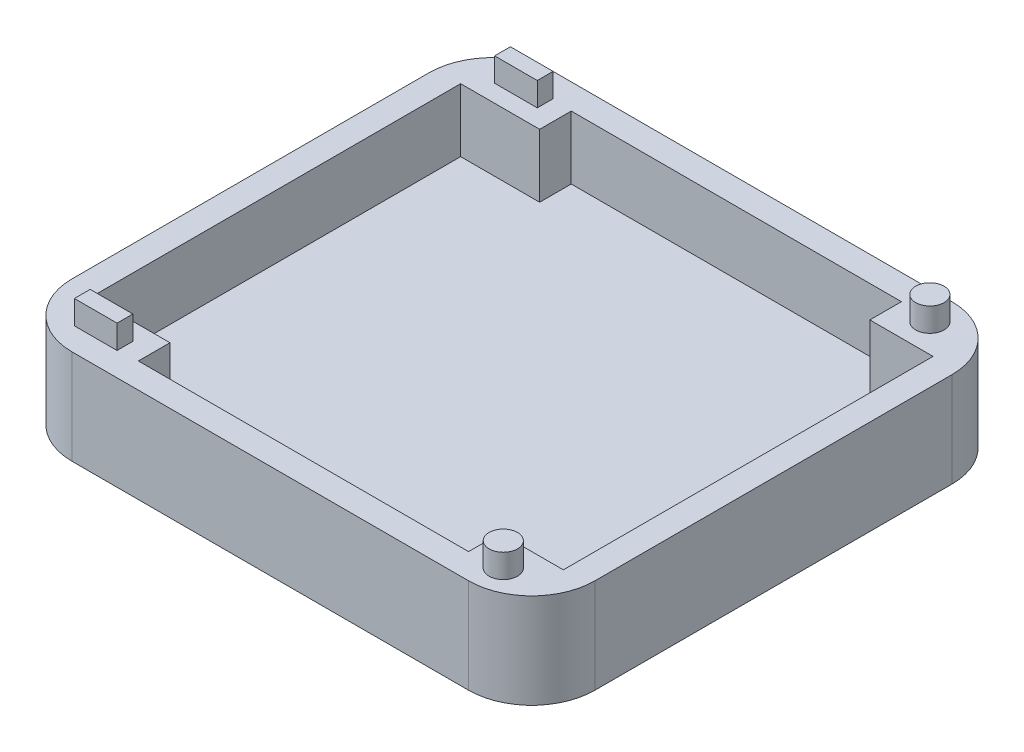
from build123d import *

# Parameters (mm, degrees)
SKETCH1_W           = 84.074
SKETCH1_H           = 77.724
BOSS_EXTRUDE1_DEPTH = 5.08
SKETCH2_W           = 84.074
SKETCH2_H           = 77.724
BOSS_EXTRUDE2_DEPTH = 10.16
FILLET1_R           = 10.16
SKETCH3_R           = 2.286
SKETCH3_W           = 6.858
SKETCH3_H           = 2.54
BOSS_EXTRUDE3_DEPTH = 3.81


with BuildPart() as part:
    # Sketch1 → Boss-Extrude1 (new body)
    with BuildSketch(Plane(origin=(0, 0, 0), x_dir=(1, 0, 0), z_dir=(0, 1, 0))):
        Rectangle(SKETCH1_W, SKETCH1_H)
    extrude(amount=BOSS_EXTRUDE1_DEPTH)

    # Sketch2 → Boss-Extrude2 (add)
    with BuildSketch(Plane(origin=(0, 5.08, 0), x_dir=(1, 0, 0), z_dir=(0, 1, 0))):
        Rectangle(SKETCH2_W, SKETCH2_H)
        Polygon((-37.973, -29.718), (-37.973, 29.718), (-25.273, 29.718), (-25.273, 34.798), (27.813, 34.798), (27.813, 29.718), (37.973, 29.718), (37.973, -29.718), (27.813, -29.718), (27.813, -34.798), (-25.273, -34.798), (-25.273, -29.718), align=None, mode=Mode.SUBTRACT)
    extrude(amount=BOSS_EXTRUDE2_DEPTH)

    # Fillet1
    fillet1_edges = [part.edges().sort_by_distance(p)[0] for p in [
        (42.037, 7.62, 38.862),
        (-42.037, 7.62, 38.862),
        (-42.037, 7.62, -38.862),
        (42.037, 7.62, -38.862),
    ]]
    fillet(fillet1_edges, radius=FILLET1_R)

    # Sketch3 → Boss-Extrude3 (add)
    with BuildSketch(Plane(origin=(0, 15.24, 0), x_dir=(1, 0, 0), z_dir=(0, 1, 0))):
        with Locations((32.893, 34.29)):
            Circle(SKETCH3_R)
        with Locations((-31.877, 33.782)):
            Rectangle(SKETCH3_W, SKETCH3_H)
    boss_extrude3 = extrude(amount=BOSS_EXTRUDE3_DEPTH)

    # Mirror1: Boss-Extrude3 across plane
    add(boss_extrude3.mirror(Plane.XY))


solid = part.part
